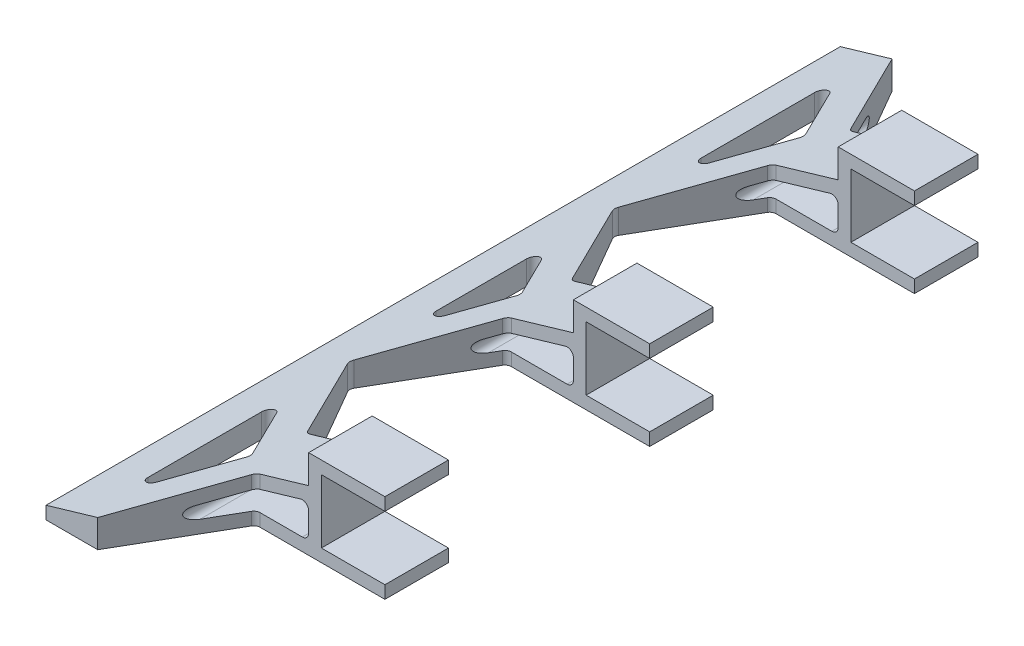
from build123d import *

# Parameters (mm, degrees)
SKETCH_1_W          = 250
SKETCH_1_H          = 4
EXTRUDE_1_DEPTH     = 20
EXTRUDE_1_2_DEPTH   = 20
SKETCH_2_W          = 250
SKETCH_2_H          = 28
EXTRUDE_2_DEPTH     = 4
SKETCH_3_W          = 250
SKETCH_3_H          = 4
EXTRUDE_3_DEPTH     = 51
EXTRUDE_4_DEPTH     = 250
CUT_EXTRUDE_1_DEPTH = 55
FILLET_1_R          = 2
CUT_EXTRUDE_2_DEPTH = 250


with BuildPart() as part:
    # 草图1 → 凸台-拉伸1 (new body)
    with BuildSketch(Plane(origin=(0, 0, 0), x_dir=(0, 0, -1), z_dir=(1, 0, 0))):
        with Locations((84.36416185, 14.963552055)):
            Rectangle(SKETCH_1_W, SKETCH_1_H)
    extrude(amount=EXTRUDE_1_DEPTH)



with BuildPart() as body_2:
    # 草图1 → Extrude 1 2 (new body)
    with BuildSketch(Plane(origin=(0, 0, 0), x_dir=(0, 0, -1), z_dir=(1, 0, 0))):
        with Locations((84.36416185, -9.036447945)):
            Rectangle(SKETCH_1_W, SKETCH_1_H)
    extrude(amount=EXTRUDE_1_2_DEPTH)


with BuildPart() as part_1:
    add(part.part)

    add(body_2.part)  # 凸台-拉伸2 merges body 2
    # 草图2 → 凸台-拉伸2 (add)
    with BuildSketch(Plane.ZY):
        with Locations((-84.36416185, 2.963552055)):
            Rectangle(SKETCH_2_W, SKETCH_2_H)
    extrude(amount=EXTRUDE_2_DEPTH)

    # 草图3 → 凸台-拉伸3 (add)
    with BuildSketch(Plane.ZY.offset(4)):
        with Locations((-84.36416185, -9.036447945)):
            Rectangle(SKETCH_3_W, SKETCH_3_H)
    extrude(amount=EXTRUDE_3_DEPTH)

    # 草图5 → 凸台-拉伸4 (add)
    with BuildSketch(Plane.XY.offset(40.63583815)):
        Polygon((-4, -7.036447945), (-55, -7.036447945), (-4, 7.963552055), align=None)
    extrude(amount=-EXTRUDE_4_DEPTH)

    # 草图7 → 切除-拉伸1 (cut)
    with BuildSketch(Plane(origin=(0, 16.963552055, 0), x_dir=(1, 0, 0), z_dir=(0, 1, 0))):
        Polygon((-38.720043801, 209.36416185), (-20.437285277, 177.697495183), (20, 177.697495183), (20, 209.36416185), align=None)
        Polygon((20, 157.697495183), (-24.717241476, 157.697495183), (-43, 126.030828516), (-24.717241476, 94.36416185), (20, 94.36416185), align=None)
        Polygon((-43, 196.77726344), (-43, 146.030828516), (-28.350766068, 171.404045978), align=None)
        Polygon((-43, 106.030828516), (-30.490744168, 84.36416185), (-43, 84.36416185), align=None)
    cut_extrude_1 = extrude(amount=-CUT_EXTRUDE_1_DEPTH, mode=Mode.SUBTRACT)

    # 镜向1: 切除-拉伸1 across plane
    add(cut_extrude_1.mirror(Plane(origin=(0, 0, -84.36416185), x_dir=(1, 0, 0), z_dir=(0, 0, -1))), mode=Mode.SUBTRACT)

    # 圆角1
    fillet_1_edges = [part_1.edges().sort_by_distance(p)[0] for p in [
        (-24.717241476, -4.583101103, -94.36416185),
        (-43, -7.271742062, -126.030828516),
        (-24.717241476, -4.583101103, -157.697495183),
        (-43, -7.271742062, -106.030828516),
        (-30.490744168, -5.432145617, -84.36416185),
        (-20.437285277, -3.95369578, -177.697495183),
        (-28.350766068, -5.117442955, 2.675722279),
        (-43, -7.271742062, 28.048939741),
        (-43, -7.271742062, -22.697495183),
        (-24.717241476, -4.583101103, -11.030828516),
        (-43, -7.271742062, -42.697495183),
        (-24.717241476, -4.583101103, -74.36416185),
        (-43, -7.271742062, -62.697495183),
        (-20.437285277, -3.95369578, 8.969171484),
        (-43, -7.271742062, -196.77726344),
        (-28.350766068, -5.117442955, -171.404045978),
        (-43, -7.271742062, -146.030828516),
    ]]
    fillet(fillet_1_edges, radius=FILLET_1_R)

    # 草图8 → 切除-拉伸2 (cut)
    with BuildSketch(Plane(origin=(0, 0, -209.36416185), x_dir=(-1, 0, 0), z_dir=(0, 0, -1))):
        with BuildLine():
            Line((4, 1.12118318), (4, -5.036447945))
            ThreePointArc((4, -5.036447945), (4.585786438, -6.450661507), (6, -7.036447945))
            Line((6, -7.036447945), (26.935945824, -7.036447945))
            ThreePointArc((26.935945824, -7.036447945), (28.915524315, -5.321525122), (27.500278472, -3.117716942))
            Line((27.500278472, -3.117716942), (6.564332648, 3.039914183))
            ThreePointArc((6.564332648, 3.039914183), (4.80180663, 2.72253656), (4, 1.12118318))
        make_face()
    extrude(amount=-CUT_EXTRUDE_2_DEPTH, mode=Mode.SUBTRACT)


solid = part_1.part
